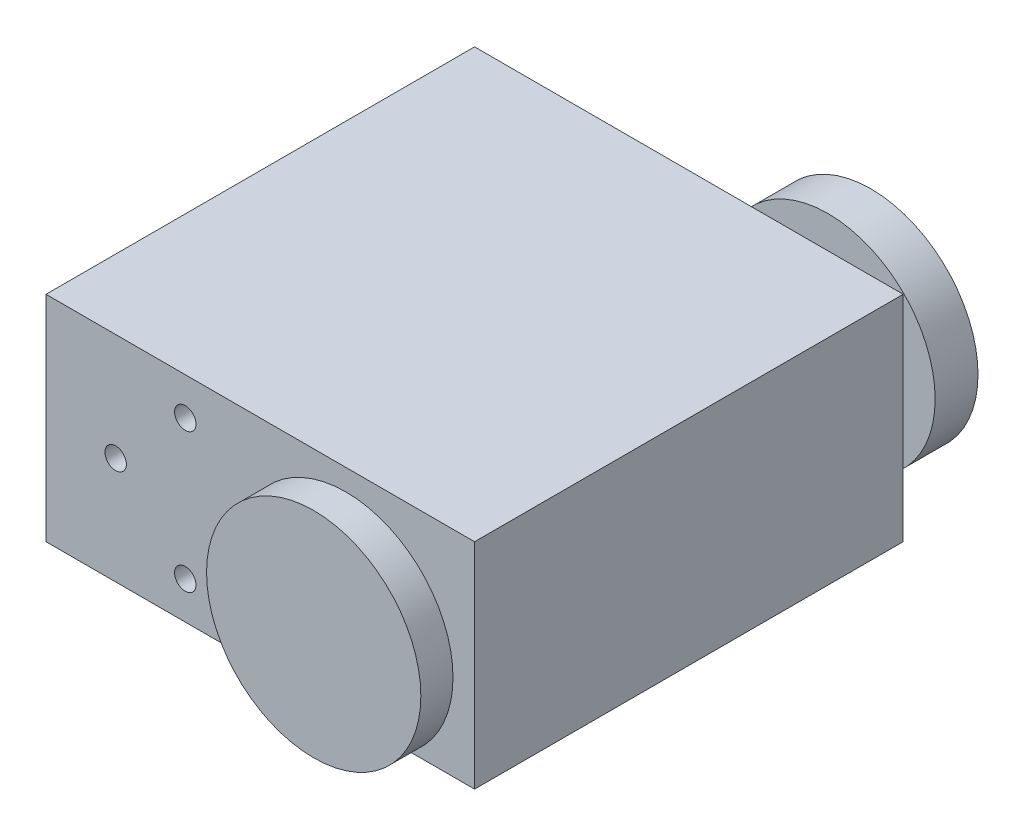
from build123d import *

# Parameters (mm, degrees)
SKETCH1_W                = 40
SKETCH1_H                = 40
BOSS_EXTRUDE1_DEPTH      = 20
SKETCH2_R                = 4
BOSS_EXTRUDE2_DEPTH      = 2
BOSS_EXTRUDE2_DEPTH_BACK = 43
SKETCH3_R                = 10
BOSS_EXTRUDE3_DEPTH      = 3
SKETCH4_R                = 10
BOSS_EXTRUDE4_DEPTH      = 4
SKETCH5_R                = 1
CUT_EXTRUDE1_DEPTH       = 5
SKETCH6_R                = 1
CUT_EXTRUDE2_DEPTH       = 5


with BuildPart() as part:
    # Sketch1 → Boss-Extrude1 (new body)
    with BuildSketch(Plane(origin=(0, 0, 0), x_dir=(1, 0, 0), z_dir=(0, 1, 0))):
        with Locations((20, 20)):
            Rectangle(SKETCH1_W, SKETCH1_H)
    extrude(amount=BOSS_EXTRUDE1_DEPTH)

    # Sketch2 → Boss-Extrude2 (add, two sides)
    with BuildSketch(Plane.XY) as boss_extrude2_sk:
        with Locations((29.985325212, 10.020295376)):
            Circle(SKETCH2_R)
    extrude(amount=BOSS_EXTRUDE2_DEPTH)
    extrude(boss_extrude2_sk.sketch, amount=-BOSS_EXTRUDE2_DEPTH_BACK)

    # Sketch3 → Boss-Extrude3 (add)
    with BuildSketch(Plane.XY.offset(2)):
        with Locations((29.985325212, 10.020295376)):
            Circle(SKETCH3_R)
    extrude(amount=BOSS_EXTRUDE3_DEPTH)

    # Sketch4 → Boss-Extrude4 (add)
    with BuildSketch(Plane(origin=(0, 0, -43), x_dir=(-1, 0, 0), z_dir=(0, 0, -1))):
        with Locations((-29.985325212, 10.020295376)):
            Circle(SKETCH4_R)
    extrude(amount=BOSS_EXTRUDE4_DEPTH)

    # Sketch5 → Cut-Extrude1 (cut)
    with BuildSketch(Plane(origin=(0, 0, -40), x_dir=(-1, 0, 0), z_dir=(0, 0, -1))):
        with Locations((-5, 18)):
            Circle(SKETCH5_R)
        with Locations((-5, 2)):
            Circle(SKETCH5_R)
        with Locations((-21, 2)):
            Circle(SKETCH5_R)
        with Locations((-21, 18)):
            Circle(SKETCH5_R)
    extrude(amount=-CUT_EXTRUDE1_DEPTH, mode=Mode.SUBTRACT)

    # Sketch6 → Cut-Extrude2 (cut)
    with BuildSketch(Plane.XY):
        with Locations((13, 16.5)):
            Circle(SKETCH6_R)
        with Locations((6.5, 10)):
            Circle(SKETCH6_R)
        with Locations((13, 3.5)):
            Circle(SKETCH6_R)
        with Locations((19.5, 10)):
            Circle(SKETCH6_R)
    extrude(amount=-CUT_EXTRUDE2_DEPTH, mode=Mode.SUBTRACT)


solid = part.part
